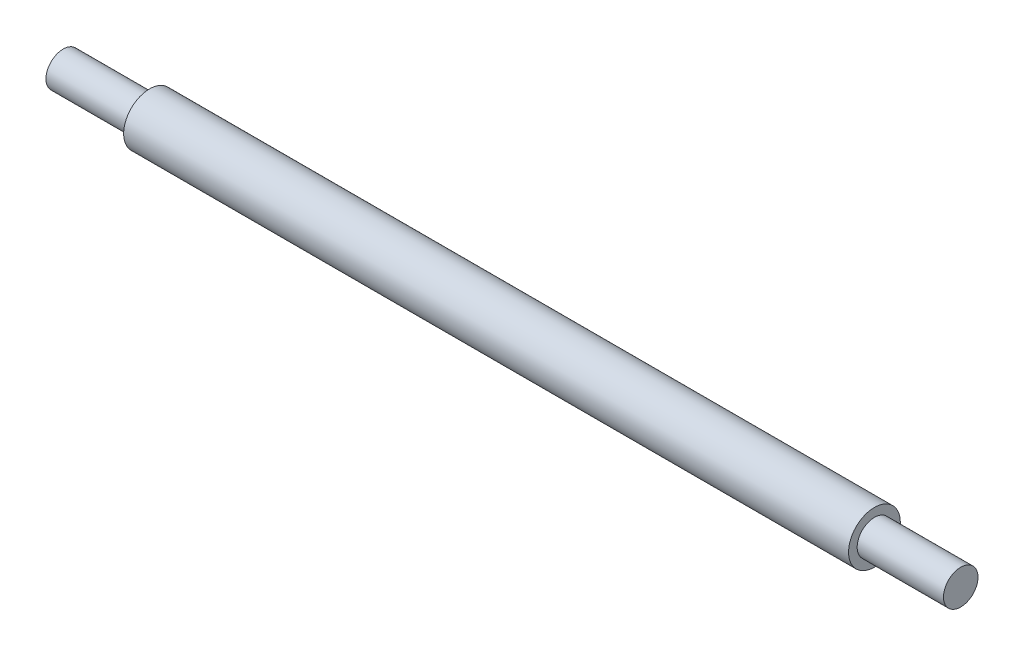
from build123d import *

# Parameters (mm, degrees)
SKETCH1_R           = 2
BOSS_EXTRUDE1_DEPTH = 10
SKETCH2_R           = 3
BOSS_EXTRUDE2_DEPTH = 84
SKETCH3_R           = 2
BOSS_EXTRUDE3_DEPTH = 10


with BuildPart() as part:
    # Sketch1 → Boss-Extrude1 (new body)
    with BuildSketch(Plane(origin=(0, 0, 0), x_dir=(0, 0, -1), z_dir=(1, 0, 0))):
        Circle(SKETCH1_R)
    extrude(amount=BOSS_EXTRUDE1_DEPTH)

    # Sketch2 → Boss-Extrude2 (add)
    with BuildSketch(Plane(origin=(10, 0, 0), x_dir=(0, 0, -1), z_dir=(1, 0, 0))):
        Circle(SKETCH2_R)
    extrude(amount=BOSS_EXTRUDE2_DEPTH)

    # Sketch3 → Boss-Extrude3 (add)
    with BuildSketch(Plane(origin=(94, 0, 0), x_dir=(0, 0, -1), z_dir=(1, 0, 0))):
        Circle(SKETCH3_R)
    extrude(amount=BOSS_EXTRUDE3_DEPTH)


solid = part.part
